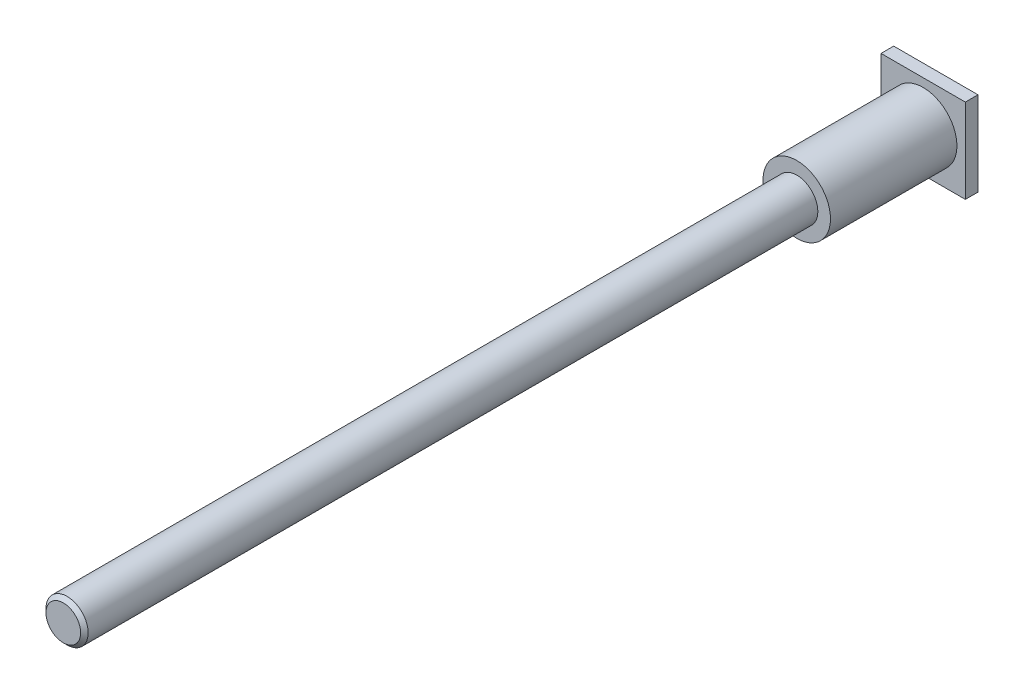
from build123d import *

# Parameters (mm, degrees)
SKETCH_1_R          = 4
EXTRUDE_1_DEPTH     = 102
SKETCH_2_W          = 10
SKETCH_2_H          = 10
EXTRUDE_2_DEPTH     = 1.5
SKETCH_6_R          = 2.055
CUT_EXTRUDE_1_DEPTH = 15
CHAMFER_1_SIZE      = 0.445
CUT_EXTRUDE_START   = 15
SKETCH_9_R          = 10
SKETCH_9_R_2        = 2.5
CUT_EXTRUDE_3_DEPTH = 88.244804269
CHAMFER1_SIZE       = 0.445


with BuildPart() as part:
    # Эскиз1 → Бобышка-Вытянуть1 (new body)
    with BuildSketch(Plane.XY):
        Circle(SKETCH_1_R)
    extrude(amount=EXTRUDE_1_DEPTH)

    # Эскиз2 → Бобышка-Вытянуть2 (add)
    with BuildSketch(Plane(origin=(0, 0, 0), x_dir=(-1, 0, 0), z_dir=(0, 0, -1))):
        Rectangle(SKETCH_2_W, SKETCH_2_H)
    extrude(amount=EXTRUDE_2_DEPTH)

    # Эскиз6 → Вырез-Вытянуть1 (cut)
    with BuildSketch(Plane(origin=(0, 0, -1.5), x_dir=(-1, 0, 0), z_dir=(0, 0, -1))):
        Circle(SKETCH_6_R)
    extrude(amount=-CUT_EXTRUDE_1_DEPTH, mode=Mode.SUBTRACT)

    # Вырез-Вытянуть2 cone 1 section (through the dimple's axis) → Вырез-Вытянуть2 (revolve, cut)
    with BuildSketch(Plane(origin=(0, 0, 13.5), x_dir=(0, 1, 0), z_dir=(1, 0, 0))):
        Polygon((0, 0), (2.055, 0), (0, 1.186454803), align=None)
    revolve(axis=Axis((0, 0, 13.5), (0, 0, 1)), mode=Mode.SUBTRACT)

    # Фаска1
    chamfer_1_edges = [part.edges().sort_by_distance(p)[0] for p in [
        (2.055, 0, -1.5),
    ]]
    chamfer(chamfer_1_edges, length=CHAMFER_1_SIZE)

    # Эскиз9 → Вырез-Вытянуть3 (cut, through all)
    with BuildSketch(Plane.XY.offset(CUT_EXTRUDE_START)):
        Circle(SKETCH_9_R)
        Circle(SKETCH_9_R_2, mode=Mode.SUBTRACT)
    extrude(amount=CUT_EXTRUDE_3_DEPTH, mode=Mode.SUBTRACT)

    # Chamfer1
    chamfer1_edges = [part.edges().sort_by_distance(p)[0] for p in [
        (-2.5, 0, 102),
    ]]
    chamfer(chamfer1_edges, length=CHAMFER1_SIZE)


solid = part.part
